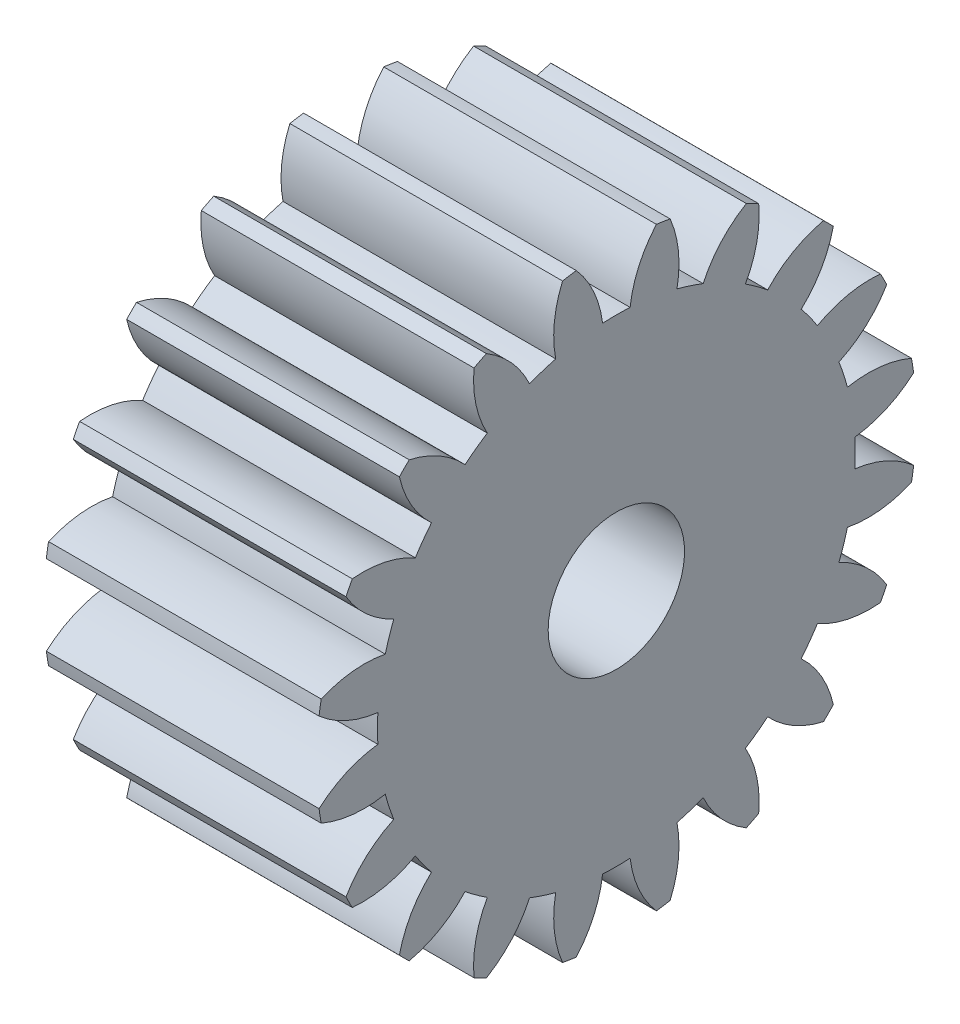
from build123d import *

# Parameters (mm, degrees)
BASPROSKE_W     = 12.7
BASPROSKE_H     = 13.97
TOOTHCUT_DEPTH  = 24.486417351
TEETHCUTS_COUNT = 20
TEETHCUTS_ANGLE = 342
BORSKE_R        = 3.175
BORE_DEPTH      = 50.8000508


with BuildPart() as part:
    # BasProSke → Base-Revolve (revolve)
    with BuildSketch(Plane(origin=(0, 0, 0), x_dir=(1, 0, 0), z_dir=(0, 1, 0)), mode=Mode.PRIVATE) as base_revolve_sk:
        with Locations((6.35, 6.985)):
            Rectangle(BASPROSKE_W, BASPROSKE_H)
    revolve(base_revolve_sk.sketch.rotate(Axis((-10, 0, 0), (1, 0, 0)), 180), axis=Axis((-10, 0, 0), (1, 0, 0)))

    # TooCutSke → ToothCut (cut, through all)
    with BuildSketch(Plane(origin=(0, 0, 0), x_dir=(0, 0, -1), z_dir=(1, 0, 0))):
        with BuildLine():
            ThreePointArc((0.64046545, 11.106749257), (0, 11.1252), (-0.64046545, 11.106749257))
            ThreePointArc((-0.64046545, 11.106749257), (-1.052455812, 12.582227662), (-1.8855699, 13.867798935))
            ThreePointArc((-1.8855699, 13.867798935), (0, 13.9954), (1.8855699, 13.867798935))
            ThreePointArc((1.8855699, 13.867798935), (1.052455812, 12.582227662), (0.64046545, 11.106749257))
        make_face()
    toothcut = extrude(amount=TOOTHCUT_DEPTH, mode=Mode.SUBTRACT)

    # TeethCuts: ToothCut ×20 about axis
    teethcuts_axis = Axis((-10, 0, 0), (1, 0, 0))
    for i in range(1, TEETHCUTS_COUNT):
        add(toothcut.rotate(teethcuts_axis, i * TEETHCUTS_ANGLE / (TEETHCUTS_COUNT - 1)), mode=Mode.SUBTRACT)

    # BorSke → Bore (cut, symmetric)
    with BuildSketch(Plane(origin=(0, 0, 0), x_dir=(0, 0, -1), z_dir=(1, 0, 0))):
        with Locations(Location((0, 0, 0), (0, 0, 180))):
            Circle(BORSKE_R)
    extrude(amount=BORE_DEPTH, both=True, mode=Mode.SUBTRACT)


solid = part.part
